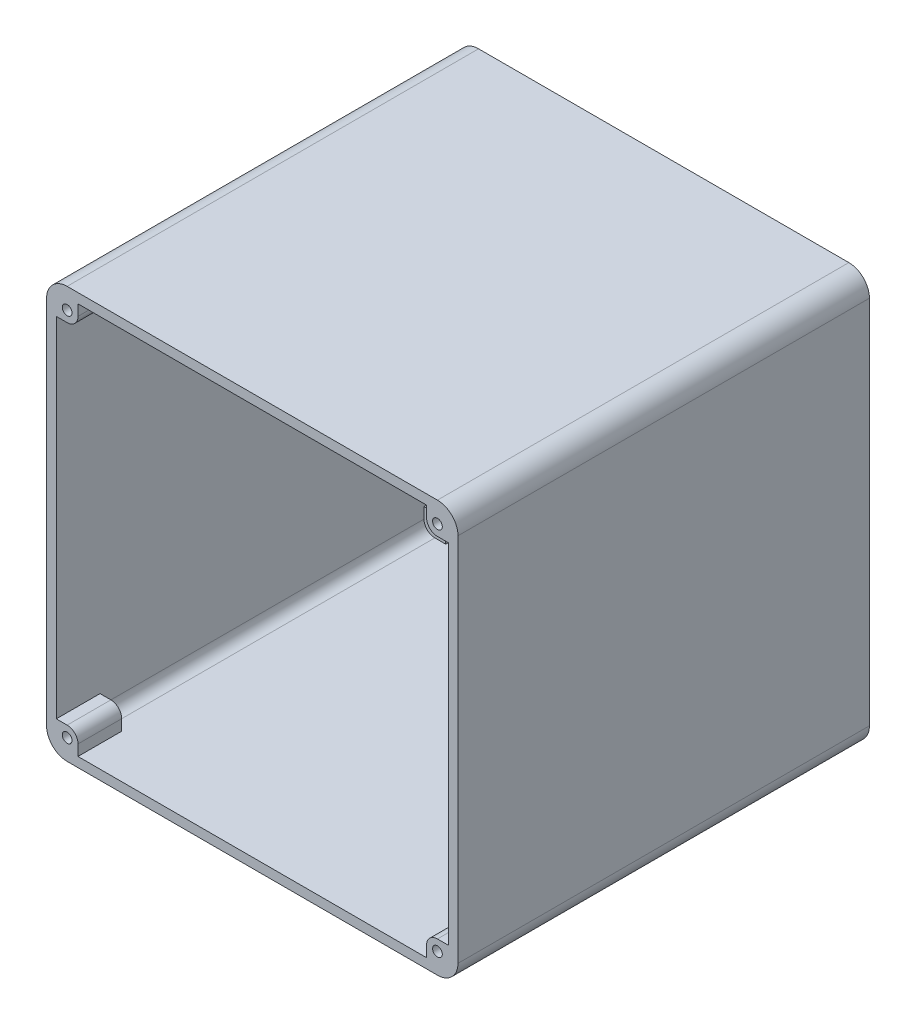
from build123d import *

# Parameters (mm, degrees)
SKETCH1_W           = 127
SKETCH1_H           = 127
SKETCH1_W_2         = 121
SKETCH1_H_2         = 121
SKETCH1_R           = 38.5
BOSS_EXTRUDE1_DEPTH = 13.5
FILLET1_R           = 6.35
SKETCH2_R           = 1.5
CUT_EXTRUDE1_DEPTH  = 91.811618199
BOSS_EXTRUDE2_DEPTH = 100
SKETCH5_R           = 1.5
BOSS_EXTRUDE3_DEPTH = 13.5


with BuildPart() as part:
    # Sketch1 → Boss-Extrude1 (new body)
    with BuildSketch(Plane.XY):
        Rectangle(SKETCH1_W, SKETCH1_H)
        Rectangle(SKETCH1_W_2, SKETCH1_H_2, mode=Mode.SUBTRACT)
        Rectangle(SKETCH1_W_2, SKETCH1_H_2)
        Circle(SKETCH1_R, mode=Mode.SUBTRACT)
        Circle(SKETCH1_R)
    extrude(amount=BOSS_EXTRUDE1_DEPTH)

    # Fillet1
    fillet1_edges = [part.edges().sort_by_distance(p)[0] for p in [
        (-63.5, 63.5, 6.75),
        (63.5, 63.5, 6.75),
        (63.5, -63.5, 6.75),
        (-63.5, -63.5, 6.75),
    ]]
    fillet(fillet1_edges, radius=FILLET1_R)

    # Sketch2 → Cut-Extrude1 (cut, through all)
    with BuildSketch(Plane.XY.offset(13.5)):
        with Locations(Location((57.15, 57.15, 0), (0, 0, 180))):
            Circle(SKETCH2_R)
        with Locations((57.15, -57.15)):
            Circle(SKETCH2_R)
        with Locations((-57.15, 57.15)):
            Circle(SKETCH2_R)
        with Locations(Location((-57.15, -57.15, 0), (0, 0, 180))):
            Circle(SKETCH2_R)
        with BuildLine():
            Line((53.8, 57.15), (53.8, 60.5))
            Line((53.8, 60.5), (-53.8, 60.5))
            Line((-53.8, 60.5), (-53.8, 57.15))
            ThreePointArc((-53.8, 57.15), (-54.781192283, 54.781192283), (-57.15, 53.8))
            Line((-57.15, 53.8), (-60.5, 53.8))
            Line((-60.5, 53.8), (-60.5, -53.8))
            Line((-60.5, -53.8), (-57.15, -53.8))
            ThreePointArc((-57.15, -53.8), (-54.781192283, -54.781192283), (-53.8, -57.15))
            Line((-53.8, -57.15), (-53.8, -60.5))
            Line((-53.8, -60.5), (53.8, -60.5))
            Line((53.8, -60.5), (53.8, -57.15))
            ThreePointArc((53.8, -57.15), (54.781192283, -54.781192283), (57.15, -53.8))
            Line((57.15, -53.8), (60.5, -53.8))
            Line((60.5, -53.8), (60.5, 53.8))
            Line((60.5, 53.8), (57.15, 53.8))
            ThreePointArc((57.15, 53.8), (54.781192283, 54.781192283), (53.8, 57.15))
        make_face()
    extrude(amount=-CUT_EXTRUDE1_DEPTH, mode=Mode.SUBTRACT)

    # Sketch4 → Boss-Extrude2 (add)
    with BuildSketch(Plane(origin=(0, 0, 0), x_dir=(-1, 0, 0), z_dir=(0, 0, -1))):
        with BuildLine():
            ThreePointArc((63.5, 57.15), (61.640128061, 61.640128061), (57.15, 63.5))
            Line((57.15, 63.5), (-57.15, 63.5))
            ThreePointArc((-57.15, 63.5), (-61.640128061, 61.640128061), (-63.5, 57.15))
            Line((-63.5, 57.15), (-63.5, -57.15))
            ThreePointArc((-63.5, -57.15), (-61.640128061, -61.640128061), (-57.15, -63.5))
            Line((-57.15, -63.5), (57.15, -63.5))
            ThreePointArc((57.15, -63.5), (61.640128061, -61.640128061), (63.5, -57.15))
            Line((63.5, -57.15), (63.5, 57.15))
        make_face()
        with BuildLine():
            Line((53.8, 60.5), (57.15, 60.5))
            ThreePointArc((57.15, 60.5), (59.518807717, 59.518807717), (60.5, 57.15))
            Line((60.5, 57.15), (60.5, 53.8))
            Line((60.5, 53.8), (60.5, -53.8))
            Line((60.5, -53.8), (60.5, -57.15))
            ThreePointArc((60.5, -57.15), (59.518807717, -59.518807717), (57.15, -60.5))
            Line((57.15, -60.5), (53.8, -60.5))
            Line((53.8, -60.5), (-53.8, -60.5))
            Line((-53.8, -60.5), (-57.15, -60.5))
            ThreePointArc((-57.15, -60.5), (-59.518807717, -59.518807717), (-60.5, -57.15))
            Line((-60.5, -57.15), (-60.5, -53.8))
            Line((-60.5, -53.8), (-60.5, 53.8))
            Line((-60.5, 53.8), (-60.5, 57.15))
            ThreePointArc((-60.5, 57.15), (-59.518807717, 59.518807717), (-57.15, 60.5))
            Line((-57.15, 60.5), (-53.8, 60.5))
            Line((-53.8, 60.5), (53.8, 60.5))
        make_face(mode=Mode.SUBTRACT)
    extrude(amount=BOSS_EXTRUDE2_DEPTH)

    # Sketch5 → Boss-Extrude3 (add)
    with BuildSketch(Plane(origin=(0, 0, -100), x_dir=(-1, 0, 0), z_dir=(0, 0, -1))):
        with BuildLine():
            Line((63.5, -57.15), (63.5, 57.15))
            ThreePointArc((63.5, 57.15), (61.640128061, 61.640128061), (57.15, 63.5))
            Line((57.15, 63.5), (-57.15, 63.5))
            ThreePointArc((-57.15, 63.5), (-61.640128061, 61.640128061), (-63.5, 57.15))
            Line((-63.5, 57.15), (-63.5, -57.15))
            ThreePointArc((-63.5, -57.15), (-61.640128061, -61.640128061), (-57.15, -63.5))
            Line((-57.15, -63.5), (57.15, -63.5))
            ThreePointArc((57.15, -63.5), (61.640128061, -61.640128061), (63.5, -57.15))
        make_face()
        with BuildLine():
            Line((-60.5, -57.15), (-60.5, 57.15))
            ThreePointArc((-60.5, 57.15), (-59.518807717, 59.518807717), (-57.15, 60.5))
            Line((-57.15, 60.5), (57.15, 60.5))
            ThreePointArc((57.15, 60.5), (59.518807717, 59.518807717), (60.5, 57.15))
            Line((60.5, 57.15), (60.5, -57.15))
            ThreePointArc((60.5, -57.15), (59.518807717, -59.518807717), (57.15, -60.5))
            Line((57.15, -60.5), (-57.15, -60.5))
            ThreePointArc((-57.15, -60.5), (-59.518807717, -59.518807717), (-60.5, -57.15))
        make_face(mode=Mode.SUBTRACT)
        with BuildLine():
            Line((-57.15, -53.8), (-60.5, -53.8))
            Line((-60.5, -53.8), (-60.5, -57.15))
            ThreePointArc((-60.5, -57.15), (-59.518807717, -59.518807717), (-57.15, -60.5))
            Line((-57.15, -60.5), (-53.8, -60.5))
            Line((-53.8, -60.5), (-53.8, -57.15))
            ThreePointArc((-53.8, -57.15), (-54.781192283, -54.781192283), (-57.15, -53.8))
        make_face()
        with Locations(Location((-57.15, -57.15, 0), (0, 0, 180))):
            Circle(SKETCH5_R, mode=Mode.SUBTRACT)
        with BuildLine():
            Line((60.5, -57.15), (60.5, -53.8))
            Line((60.5, -53.8), (57.15, -53.8))
            ThreePointArc((57.15, -53.8), (54.781192283, -54.781192283), (53.8, -57.15))
            Line((53.8, -57.15), (53.8, -60.5))
            Line((53.8, -60.5), (57.15, -60.5))
            ThreePointArc((57.15, -60.5), (59.518807717, -59.518807717), (60.5, -57.15))
        make_face()
        with Locations((57.15, -57.15)):
            Circle(SKETCH5_R, mode=Mode.SUBTRACT)
        with BuildLine():
            Line((57.15, 60.5), (53.8, 60.5))
            Line((53.8, 60.5), (53.8, 57.15))
            ThreePointArc((53.8, 57.15), (54.781192283, 54.781192283), (57.15, 53.8))
            Line((57.15, 53.8), (60.5, 53.8))
            Line((60.5, 53.8), (60.5, 57.15))
            ThreePointArc((60.5, 57.15), (59.518807717, 59.518807717), (57.15, 60.5))
        make_face()
        with Locations(Location((57.15, 57.15, 0), (0, 0, 180))):
            Circle(SKETCH5_R, mode=Mode.SUBTRACT)
        with BuildLine():
            Line((-53.8, 57.15), (-53.8, 60.5))
            Line((-53.8, 60.5), (-57.15, 60.5))
            ThreePointArc((-57.15, 60.5), (-59.518807717, 59.518807717), (-60.5, 57.15))
            Line((-60.5, 57.15), (-60.5, 53.8))
            Line((-60.5, 53.8), (-57.15, 53.8))
            ThreePointArc((-57.15, 53.8), (-54.781192283, 54.781192283), (-53.8, 57.15))
        make_face()
        with Locations((-57.15, 57.15)):
            Circle(SKETCH5_R, mode=Mode.SUBTRACT)
    extrude(amount=BOSS_EXTRUDE3_DEPTH)


solid = part.part
